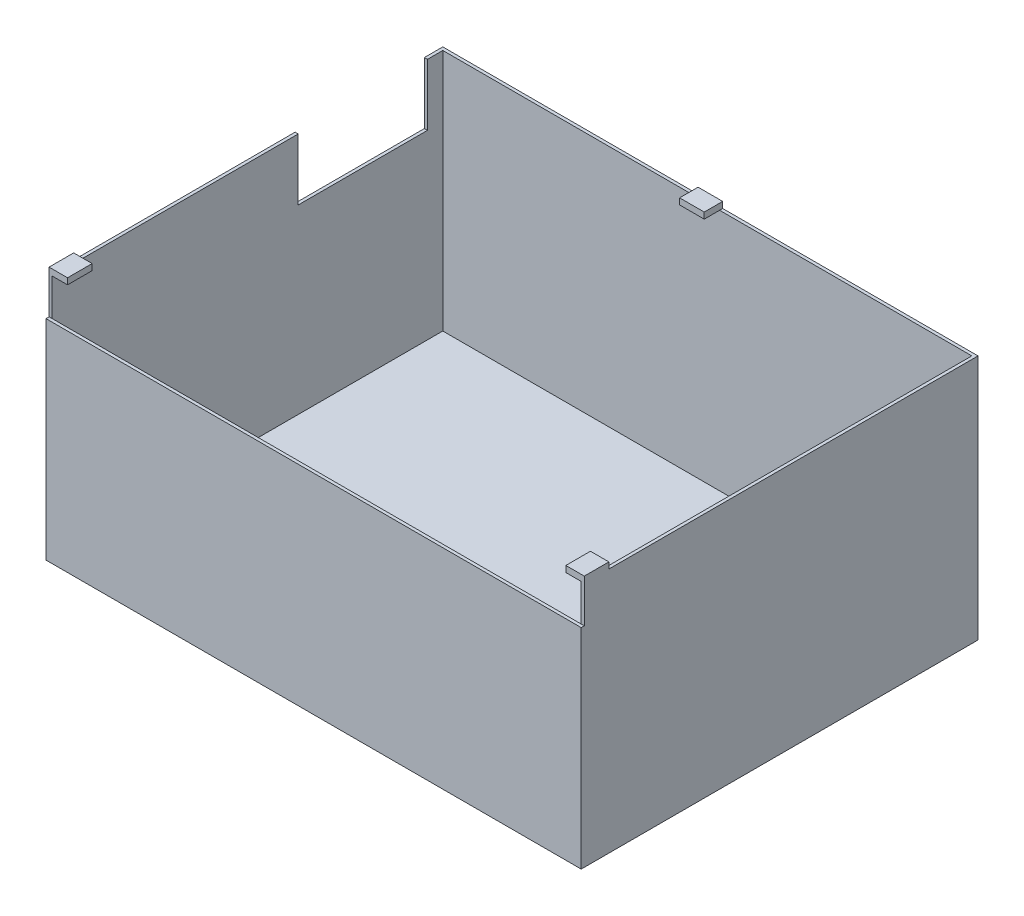
from build123d import *

# Parameters (mm, degrees)
SKETCH1_W           = 172
SKETCH1_H           = 127
BOSS_EXTRUDE1_DEPTH = 1
BOSS_EXTRUDE2_DEPTH = 80
BOSS_EXTRUDE3_DEPTH = 68
SKETCH4_W           = 6
SKETCH4_H           = 8
SKETCH4_W_2         = 8
SKETCH4_H_2         = 6
BOSS_EXTRUDE4_DEPTH = 2
SKETCH5_W           = 42
SKETCH5_H           = 20
CUT_EXTRUDE1_DEPTH  = 10


with BuildPart() as part:
    # Sketch1 → Boss-Extrude1 (new body)
    with BuildSketch(Plane(origin=(0, 0, 0), x_dir=(1, 0, 0), z_dir=(0, 1, 0))):
        with Locations((86, 63.5)):
            Rectangle(SKETCH1_W, SKETCH1_H)
    extrude(amount=BOSS_EXTRUDE1_DEPTH)

    # Sketch1_3 → Boss-Extrude2 (add)
    with BuildSketch(Plane(origin=(0, 0, 0), x_dir=(1, 0, 0), z_dir=(0, 1, 0))):
        Polygon((-1, 128), (-1, 0), (0, 0), (0, 127), (172, 127), (172, 0), (173, 0), (173, 128), align=None)
    extrude(amount=BOSS_EXTRUDE2_DEPTH)

    # Sketch1_4 → Boss-Extrude3 (add)
    with BuildSketch(Plane(origin=(0, 0, 0), x_dir=(1, 0, 0), z_dir=(0, 1, 0))):
        Polygon((-1, 0), (-1, -1), (173, -1), (173, 0), (172, 0), (0, 0), align=None)
    extrude(amount=BOSS_EXTRUDE3_DEPTH)

    # Sketch4 → Boss-Extrude4 (add)
    with BuildSketch(Plane(origin=(0, 80, 0), x_dir=(1, 0, 0), z_dir=(0, 1, 0))):
        with Locations((2, 4)):
            Rectangle(SKETCH4_W, SKETCH4_H)
        with Locations((170, 4)):
            Rectangle(SKETCH4_W, SKETCH4_H)
        with Locations((86, 125)):
            Rectangle(SKETCH4_W_2, SKETCH4_H_2)
    extrude(amount=BOSS_EXTRUDE4_DEPTH)

    # Sketch5 → Cut-Extrude1 (cut)
    with BuildSketch(Plane.ZY.offset(1)):
        with Locations((-101, 70)):
            Rectangle(SKETCH5_W, SKETCH5_H)
    extrude(amount=-CUT_EXTRUDE1_DEPTH, mode=Mode.SUBTRACT)


solid = part.part
